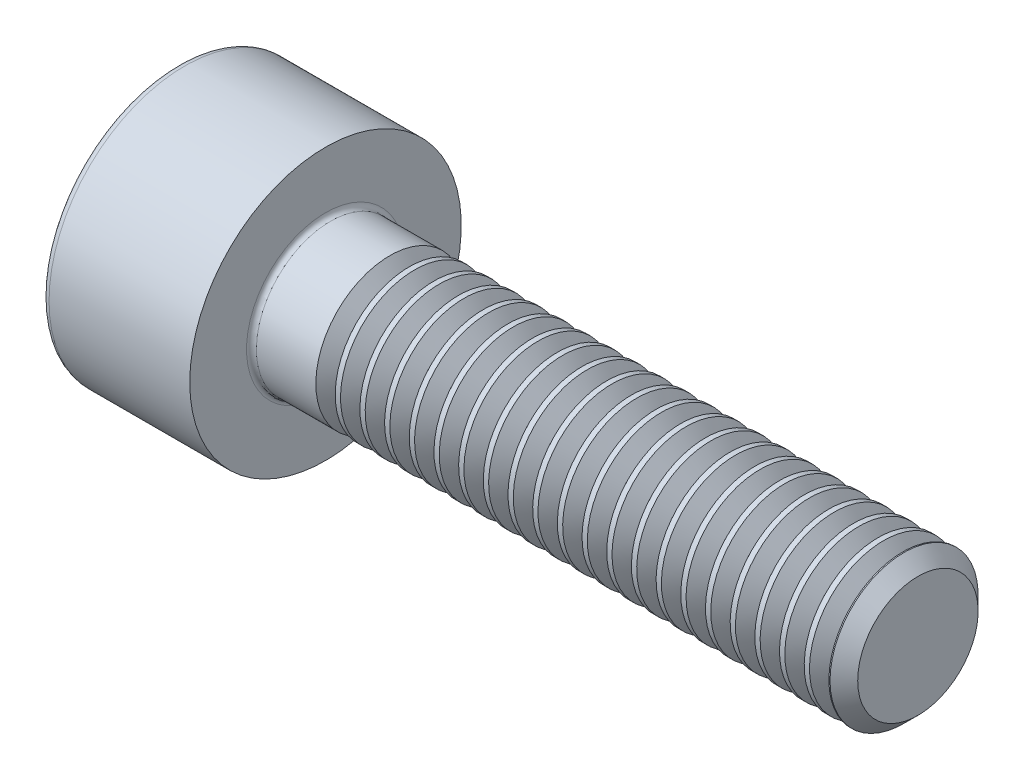
from build123d import *

# Parameters (mm, degrees)
FILLET1_R       = 0.1
FILLET2_R       = 0.15
HEX_2_DEPTH     = 1.3
THDSCHPAT_COUNT = 21
THDSCHPAT_PITCH = 0.5


with BuildPart() as part:
    # BodySke → Base-Revolve (revolve)
    with BuildSketch(Plane.XY):
        Polygon((0, 0), (0, 2.75), (3, 2.75), (3, 1.5), (14.7195, 1.5), (15, 1.2195), (15, 0), align=None)
    revolve(axis=Axis((-31.75, 0, 0), (1, 0, 0)))

    # Fillet1
    fillet1_edges = [part.edges().sort_by_distance(p)[0] for p in [
        (3, -1.5, 0),
    ]]
    fillet(fillet1_edges, radius=FILLET1_R)

    # Fillet2
    fillet2_edges = [part.edges().sort_by_distance(p)[0] for p in [
        (0, -2.75, 0),
    ]]
    fillet(fillet2_edges, radius=FILLET2_R)

    # Sketch2 → Hex-PreBroach (revolve, cut)
    with BuildSketch(Plane.XY):
        Polygon((0, 1.28), (1.3, 1.28), (2.039008345, 0), (0, 0), align=None)
    revolve(axis=Axis((0, 0, 0), (1, 0, 0)), mode=Mode.SUBTRACT)

    # Sketch3 → Hex 2 (cut)
    with BuildSketch(Plane(origin=(0, 0, 0), x_dir=(0, 0.5, 0.866025404), z_dir=(-1, 0, 0))):
        Polygon((0.739008345, 1.28), (-0.739008345, 1.28), (-1.478016689, 0), (-0.739008345, -1.28), (0.739008345, -1.28), (1.478016689, 0), align=None)
    extrude(amount=-HEX_2_DEPTH, mode=Mode.SUBTRACT)

    # ThdSchSke → ThreadSchematic (revolve, cut)
    with BuildSketch(Plane.XY):
        Polygon((4.5, -1.2195), (4.303591786, -1.5), (4.303591786, -1.875), (4.696408214, -1.875), (4.696408214, -1.5), align=None)
    threadschematic = revolve(axis=Axis((-3.175, 0, 0), (1, 0, 0)), mode=Mode.SUBTRACT)

    # ThdSchPat: ThreadSchematic ×21
    with Locations(*[(i * THDSCHPAT_PITCH, 0, 0) for i in range(1, THDSCHPAT_COUNT)]):
        add(threadschematic, mode=Mode.SUBTRACT)


solid = part.part
